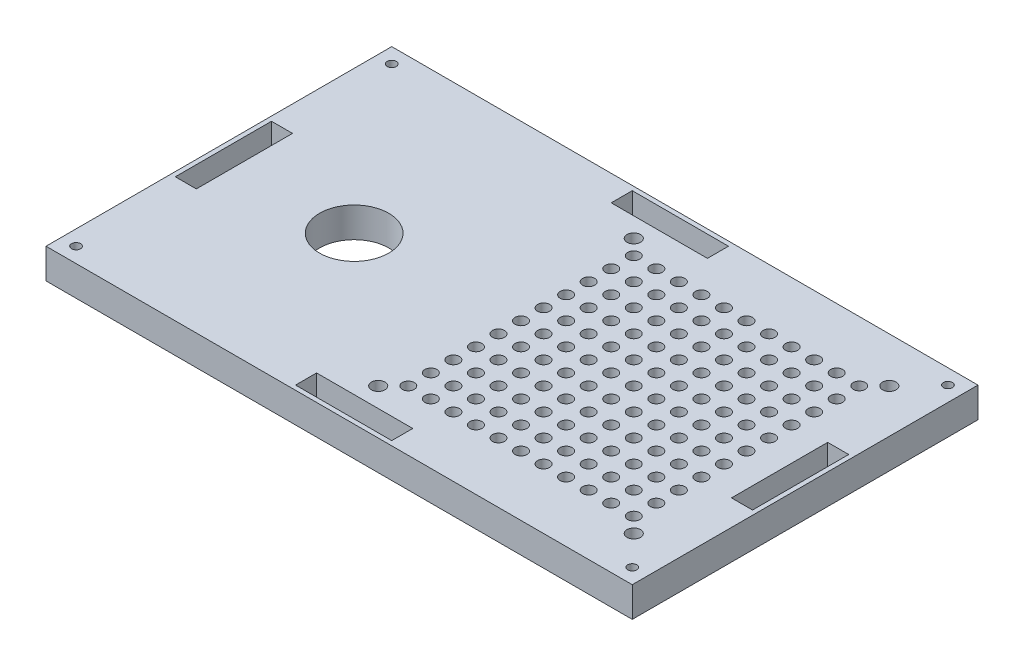
from build123d import *

# Parameters (mm, degrees)
ESBO_O1_W                = 195
ESBO_O1_H                = 115
RESSALTO_EXTRUS_O1_DEPTH = 10
ESBO_O2_R                = 1.5
ESBO_O2_W                = 7
ESBO_O2_H                = 32
ESBO_O2_W_2              = 32
ESBO_O2_H_2              = 7
CORTE_EXTRUS_O2_DEPTH    = 11
ESBO_O3_R                = 2.25
ESBO_O3_R_2              = 2
ESBO_O3_R_3              = 11.5
CORTE_EXTRUS_O3_DEPTH    = 11


with BuildPart() as part:
    # Esboço1 → Ressalto-extrusão1 (new body)
    with BuildSketch(Plane(origin=(0, 0, 0), x_dir=(1, 0, 0), z_dir=(0, 1, 0))):
        Rectangle(ESBO_O1_W, ESBO_O1_H)
    extrude(amount=RESSALTO_EXTRUS_O1_DEPTH)

    # Esboço2 → Corte-extrusão2 (cut, through all)
    with BuildSketch(Plane(origin=(0, 10, 0), x_dir=(1, 0, 0), z_dir=(0, 1, 0))):
        with Locations((-92.5, 52.5)):
            Circle(ESBO_O2_R)
        with Locations((92.5, 52.5)):
            Circle(ESBO_O2_R)
        with Locations((92.5, -52.5)):
            Circle(ESBO_O2_R)
        with Locations((-92.5, -52.5)):
            Circle(ESBO_O2_R)
        with Locations((-92.5, 0)):
            Rectangle(ESBO_O2_W, ESBO_O2_H)
        with Locations((0, -52.5)):
            Rectangle(ESBO_O2_W_2, ESBO_O2_H_2)
        with Locations((92.5, 0)):
            Rectangle(ESBO_O2_W, ESBO_O2_H)
        with Locations((0, 52.5)):
            Rectangle(ESBO_O2_W_2, ESBO_O2_H_2)
    extrude(amount=-CORTE_EXTRUS_O2_DEPTH, mode=Mode.SUBTRACT)

    # Esboço3 → Corte-extrusão3 (cut, through all)
    with BuildSketch(Plane(origin=(0, 10, 0), x_dir=(1, 0, 0), z_dir=(0, 1, 0))):
        with Locations((83, 42.5)):
            Circle(ESBO_O3_R)
        with Locations((83, -42.5)):
            Circle(ESBO_O3_R)
        with Locations((-2, -42.5)):
            Circle(ESBO_O3_R)
        with Locations((-2, 42.5)):
            Circle(ESBO_O3_R)
        with Locations((3, 37.5)):
            Circle(ESBO_O3_R_2)
        with Locations((10.5, 37.5)):
            Circle(ESBO_O3_R_2)
        with Locations((18, 37.5)):
            Circle(ESBO_O3_R_2)
        with Locations((25.5, 37.5)):
            Circle(ESBO_O3_R_2)
        with Locations((33, 37.5)):
            Circle(ESBO_O3_R_2)
        with Locations((40.5, 37.5)):
            Circle(ESBO_O3_R_2)
        with Locations((48, 37.5)):
            Circle(ESBO_O3_R_2)
        with Locations((55.5, 37.5)):
            Circle(ESBO_O3_R_2)
        with Locations((63, 37.5)):
            Circle(ESBO_O3_R_2)
        with Locations((70.5, 37.5)):
            Circle(ESBO_O3_R_2)
        with Locations((78, 37.5)):
            Circle(ESBO_O3_R_2)
        with Locations((10.5, 30)):
            Circle(ESBO_O3_R_2)
        with Locations((18, 30)):
            Circle(ESBO_O3_R_2)
        with Locations((25.5, 30)):
            Circle(ESBO_O3_R_2)
        with Locations((33, 30)):
            Circle(ESBO_O3_R_2)
        with Locations((40.5, 30)):
            Circle(ESBO_O3_R_2)
        with Locations((48, 30)):
            Circle(ESBO_O3_R_2)
        with Locations((55.5, 30)):
            Circle(ESBO_O3_R_2)
        with Locations((63, 30)):
            Circle(ESBO_O3_R_2)
        with Locations((70.5, 30)):
            Circle(ESBO_O3_R_2)
        with Locations((78, 30)):
            Circle(ESBO_O3_R_2)
        with Locations((10.5, 22.5)):
            Circle(ESBO_O3_R_2)
        with Locations((18, 22.5)):
            Circle(ESBO_O3_R_2)
        with Locations((25.5, 22.5)):
            Circle(ESBO_O3_R_2)
        with Locations((33, 22.5)):
            Circle(ESBO_O3_R_2)
        with Locations((40.5, 22.5)):
            Circle(ESBO_O3_R_2)
        with Locations((48, 22.5)):
            Circle(ESBO_O3_R_2)
        with Locations((55.5, 22.5)):
            Circle(ESBO_O3_R_2)
        with Locations((63, 22.5)):
            Circle(ESBO_O3_R_2)
        with Locations((70.5, 22.5)):
            Circle(ESBO_O3_R_2)
        with Locations((78, 22.5)):
            Circle(ESBO_O3_R_2)
        with Locations((10.5, 15)):
            Circle(ESBO_O3_R_2)
        with Locations((18, 15)):
            Circle(ESBO_O3_R_2)
        with Locations((25.5, 15)):
            Circle(ESBO_O3_R_2)
        with Locations((33, 15)):
            Circle(ESBO_O3_R_2)
        with Locations((40.5, 15)):
            Circle(ESBO_O3_R_2)
        with Locations((48, 15)):
            Circle(ESBO_O3_R_2)
        with Locations((55.5, 15)):
            Circle(ESBO_O3_R_2)
        with Locations((63, 15)):
            Circle(ESBO_O3_R_2)
        with Locations((70.5, 15)):
            Circle(ESBO_O3_R_2)
        with Locations((78, 15)):
            Circle(ESBO_O3_R_2)
        with Locations((10.5, 7.5)):
            Circle(ESBO_O3_R_2)
        with Locations((18, 7.5)):
            Circle(ESBO_O3_R_2)
        with Locations((25.5, 7.5)):
            Circle(ESBO_O3_R_2)
        with Locations((33, 7.5)):
            Circle(ESBO_O3_R_2)
        with Locations((40.5, 7.5)):
            Circle(ESBO_O3_R_2)
        with Locations((48, 7.5)):
            Circle(ESBO_O3_R_2)
        with Locations((55.5, 7.5)):
            Circle(ESBO_O3_R_2)
        with Locations((63, 7.5)):
            Circle(ESBO_O3_R_2)
        with Locations((70.5, 7.5)):
            Circle(ESBO_O3_R_2)
        with Locations((78, 7.5)):
            Circle(ESBO_O3_R_2)
        with Locations((10.5, 0)):
            Circle(ESBO_O3_R_2)
        with Locations((18, 0)):
            Circle(ESBO_O3_R_2)
        with Locations((25.5, 0)):
            Circle(ESBO_O3_R_2)
        with Locations((33, 0)):
            Circle(ESBO_O3_R_2)
        with Locations((40.5, 0)):
            Circle(ESBO_O3_R_2)
        with Locations((48, 0)):
            Circle(ESBO_O3_R_2)
        with Locations((55.5, 0)):
            Circle(ESBO_O3_R_2)
        with Locations((63, 0)):
            Circle(ESBO_O3_R_2)
        with Locations((70.5, 0)):
            Circle(ESBO_O3_R_2)
        with Locations((78, 0)):
            Circle(ESBO_O3_R_2)
        with Locations((10.5, -7.5)):
            Circle(ESBO_O3_R_2)
        with Locations((18, -7.5)):
            Circle(ESBO_O3_R_2)
        with Locations((25.5, -7.5)):
            Circle(ESBO_O3_R_2)
        with Locations((33, -7.5)):
            Circle(ESBO_O3_R_2)
        with Locations((40.5, -7.5)):
            Circle(ESBO_O3_R_2)
        with Locations((48, -7.5)):
            Circle(ESBO_O3_R_2)
        with Locations((55.5, -7.5)):
            Circle(ESBO_O3_R_2)
        with Locations((63, -7.5)):
            Circle(ESBO_O3_R_2)
        with Locations((70.5, -7.5)):
            Circle(ESBO_O3_R_2)
        with Locations((78, -7.5)):
            Circle(ESBO_O3_R_2)
        with Locations((10.5, -15)):
            Circle(ESBO_O3_R_2)
        with Locations((18, -15)):
            Circle(ESBO_O3_R_2)
        with Locations((25.5, -15)):
            Circle(ESBO_O3_R_2)
        with Locations((33, -15)):
            Circle(ESBO_O3_R_2)
        with Locations((40.5, -15)):
            Circle(ESBO_O3_R_2)
        with Locations((48, -15)):
            Circle(ESBO_O3_R_2)
        with Locations((55.5, -15)):
            Circle(ESBO_O3_R_2)
        with Locations((63, -15)):
            Circle(ESBO_O3_R_2)
        with Locations((70.5, -15)):
            Circle(ESBO_O3_R_2)
        with Locations((78, -15)):
            Circle(ESBO_O3_R_2)
        with Locations((10.5, -22.5)):
            Circle(ESBO_O3_R_2)
        with Locations((18, -22.5)):
            Circle(ESBO_O3_R_2)
        with Locations((25.5, -22.5)):
            Circle(ESBO_O3_R_2)
        with Locations((33, -22.5)):
            Circle(ESBO_O3_R_2)
        with Locations((40.5, -22.5)):
            Circle(ESBO_O3_R_2)
        with Locations((48, -22.5)):
            Circle(ESBO_O3_R_2)
        with Locations((55.5, -22.5)):
            Circle(ESBO_O3_R_2)
        with Locations((63, -22.5)):
            Circle(ESBO_O3_R_2)
        with Locations((70.5, -22.5)):
            Circle(ESBO_O3_R_2)
        with Locations((78, -22.5)):
            Circle(ESBO_O3_R_2)
        with Locations((10.5, -30)):
            Circle(ESBO_O3_R_2)
        with Locations((18, -30)):
            Circle(ESBO_O3_R_2)
        with Locations((25.5, -30)):
            Circle(ESBO_O3_R_2)
        with Locations((33, -30)):
            Circle(ESBO_O3_R_2)
        with Locations((40.5, -30)):
            Circle(ESBO_O3_R_2)
        with Locations((48, -30)):
            Circle(ESBO_O3_R_2)
        with Locations((55.5, -30)):
            Circle(ESBO_O3_R_2)
        with Locations((63, -30)):
            Circle(ESBO_O3_R_2)
        with Locations((70.5, -30)):
            Circle(ESBO_O3_R_2)
        with Locations((78, -30)):
            Circle(ESBO_O3_R_2)
        with Locations((10.5, -37.5)):
            Circle(ESBO_O3_R_2)
        with Locations((18, -37.5)):
            Circle(ESBO_O3_R_2)
        with Locations((25.5, -37.5)):
            Circle(ESBO_O3_R_2)
        with Locations((33, -37.5)):
            Circle(ESBO_O3_R_2)
        with Locations((40.5, -37.5)):
            Circle(ESBO_O3_R_2)
        with Locations((48, -37.5)):
            Circle(ESBO_O3_R_2)
        with Locations((55.5, -37.5)):
            Circle(ESBO_O3_R_2)
        with Locations((63, -37.5)):
            Circle(ESBO_O3_R_2)
        with Locations((70.5, -37.5)):
            Circle(ESBO_O3_R_2)
        with Locations((78, -37.5)):
            Circle(ESBO_O3_R_2)
        with Locations((3, 30)):
            Circle(ESBO_O3_R_2)
        with Locations((3, 22.5)):
            Circle(ESBO_O3_R_2)
        with Locations((3, 15)):
            Circle(ESBO_O3_R_2)
        with Locations((3, 7.5)):
            Circle(ESBO_O3_R_2)
        with Locations((3, 0)):
            Circle(ESBO_O3_R_2)
        with Locations((3, -7.5)):
            Circle(ESBO_O3_R_2)
        with Locations((3, -15)):
            Circle(ESBO_O3_R_2)
        with Locations((3, -22.5)):
            Circle(ESBO_O3_R_2)
        with Locations((3, -30)):
            Circle(ESBO_O3_R_2)
        with Locations((3, -37.5)):
            Circle(ESBO_O3_R_2)
        with Locations((-50, -2.5)):
            Circle(ESBO_O3_R_3)
    extrude(amount=-CORTE_EXTRUS_O3_DEPTH, mode=Mode.SUBTRACT)


solid = part.part
